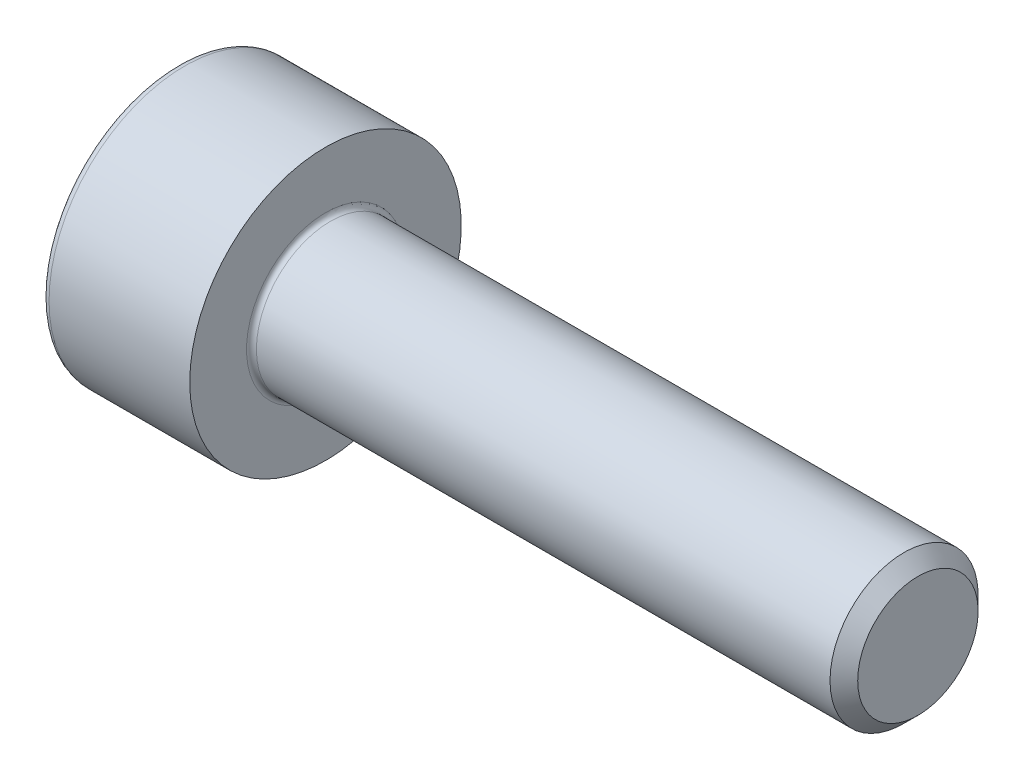
from build123d import *

# Parameters (mm, degrees)
FILLET1_R   = 0.1
FILLET2_R   = 0.15
HEX_2_DEPTH = 1.3


with BuildPart() as part:
    # BodySke → Base-Revolve (revolve)
    with BuildSketch(Plane.XY, mode=Mode.PRIVATE) as base_revolve_sk:
        Polygon((0, 0), (0, 2.75), (3, 2.75), (3, 1.5), (14.7195, 1.5), (15, 1.2195), (15, 0), align=None)
    revolve(base_revolve_sk.sketch.rotate(Axis((-31.75, 0, 0), (1, 0, 0)), 90), axis=Axis((-31.75, 0, 0), (1, 0, 0)))  # turned: the seam where the file's is

    # Fillet1
    fillet1_edges = [part.edges().sort_by_distance(p)[0] for p in [
        (3, 0, -1.5),
    ]]
    fillet(fillet1_edges, radius=FILLET1_R)

    # Fillet2
    fillet2_edges = [part.edges().sort_by_distance(p)[0] for p in [
        (0, 0, -2.75),
    ]]
    fillet(fillet2_edges, radius=FILLET2_R)

    # Sketch2 → Hex-PreBroach (revolve, cut)
    with BuildSketch(Plane.XY, mode=Mode.PRIVATE) as hex_prebroach_sk:
        Polygon((0, 1.28), (1.3, 1.28), (2.039008345, 0), (0, 0), align=None)
    revolve(hex_prebroach_sk.sketch.rotate(Axis((0, 0, 0), (1, 0, 0)), 90), axis=Axis((0, 0, 0), (1, 0, 0)), mode=Mode.SUBTRACT)  # turned: the seam where the file's is

    # Sketch3 → Hex 2 (cut)
    with BuildSketch(Plane(origin=(0, 0, 0), x_dir=(0, 0.5, 0.866025404), z_dir=(-1, 0, 0))):
        Polygon((0.739008345, 1.28), (-0.739008345, 1.28), (-1.478016689, 0), (-0.739008345, -1.28), (0.739008345, -1.28), (1.478016689, 0), align=None)
    extrude(amount=-HEX_2_DEPTH, mode=Mode.SUBTRACT)


solid = part.part
